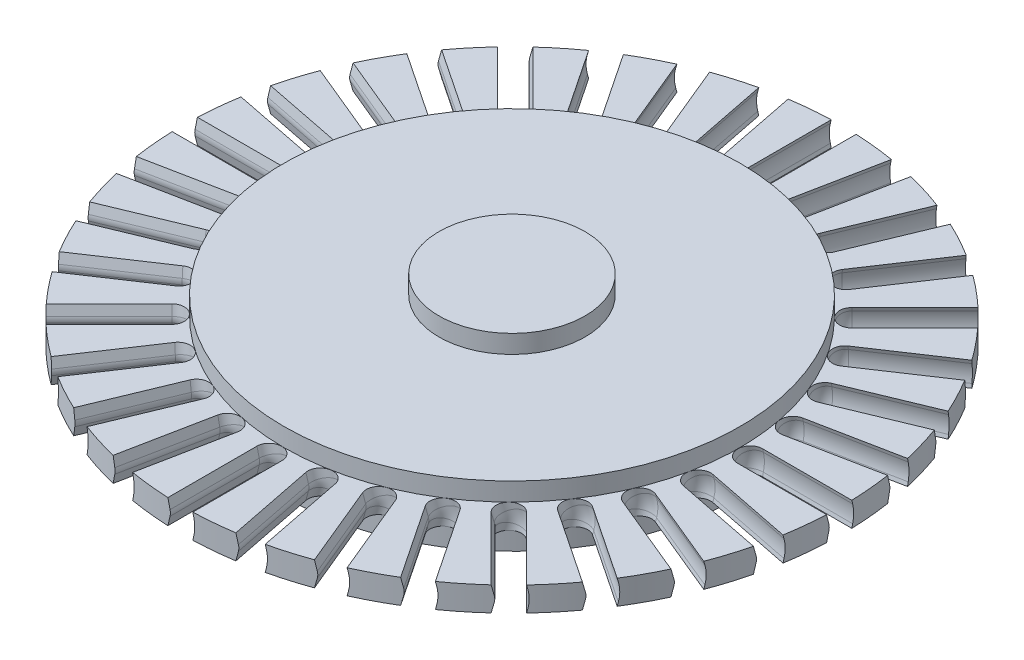
from build123d import *

# Parameters (mm, degrees)
SKETCH4_W    = 19.05
SKETCH4_H    = 25.4
SKETCH4_W_2  = 26.4922
SKETCH4_H_2  = 6.35
BLADES_COUNT = 32


with BuildPart() as part:
    # Sketch4 → Disc (revolve)
    with BuildSketch(Plane.XY):
        with Locations((9.525, 0)):
            Rectangle(SKETCH4_W, SKETCH4_H)
        with Locations((72.7075, 0)):
            Rectangle(SKETCH4_W_2, SKETCH4_H_2)
        Polygon((59.4614, -7.9375), (59.4614, -3.175), (59.4614, 3.175), (59.4614, 7.9375), (19.05, 7.9375), (19.05, -7.9375), align=None)
    revolve(axis=Axis((0, 0, 0), (0, 1, 0)))

    # Blade Cutout: sweep along a path in Sketch9
    with BuildLine(Plane(origin=(85.9536, 0, 0), x_dir=(0, 0, -1), z_dir=(1, 0, 0))) as blade_cutout_path:
        Line((-2.889269413, 12.7), (-0.178047646, 1.493152418))
        ThreePointArc((-0.178047646, 1.493152418), (0, 0), (-0.178047646, -1.493152418))
        Line((-0.178047646, -1.493152418), (-2.889269413, -12.7))
    # Endmill → Blade Cutout (sweep, cut)
    with BuildSketch(Plane(origin=(0, 0, 0), x_dir=(1, 0, 0), z_dir=(0, 1, 0))):
        with BuildLine():
            Line((110.2614, 3.175), (62.6364, 3.175))
            ThreePointArc((62.6364, 3.175), (59.4614, 0), (62.6364, -3.175))
            Line((62.6364, -3.175), (110.2614, -3.175))
            Line((110.2614, -3.175), (110.2614, 3.175))
        make_face()
    blade_cutout = sweep(path=blade_cutout_path.line, mode=Mode.SUBTRACT)

    # Blades: Blade Cutout ×32 about axis
    blades_axis = Axis((0, 13.97, 0), (0, -1, 0))
    for i in range(1, BLADES_COUNT):
        add(blade_cutout.rotate(blades_axis, i * 360 / BLADES_COUNT), mode=Mode.SUBTRACT)


solid = part.part
